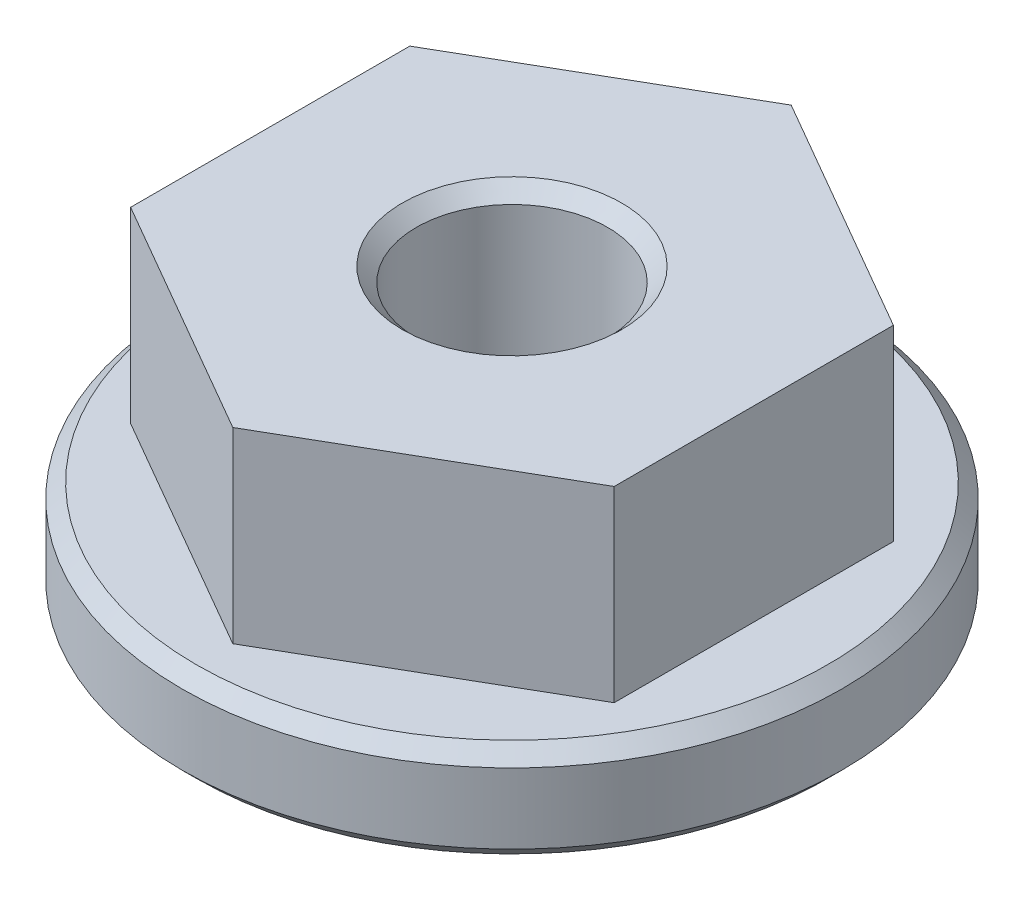
from build123d import *

# Parameters (mm, degrees)
SKETCH1_R             = 5.953125
BOSS_EXTRUDE1_DEPTH   = 1.778
BOSS_EXTRUDE2_DEPTH   = 3.381375
F_8_32_TAPPED_HOLE1_D = 3.4544
CHAMFER1_SIZE         = 0.254


with BuildPart() as part:
    # Sketch1 → Boss-Extrude1 (new body)
    with BuildSketch(Plane(origin=(0, 0, 0), x_dir=(1, 0, 0), z_dir=(0, 1, 0))):
        Circle(SKETCH1_R)
    extrude(amount=BOSS_EXTRUDE1_DEPTH)

    # Sketch2 → Boss-Extrude2 (add)
    with BuildSketch(Plane(origin=(0, 1.778, 0), x_dir=(1, 0, 0), z_dir=(0, 1, 0))):
        Polygon((4.365625, -2.520494769), (4.365625, 2.520494769), (0, 5.040989538), (-4.365625, 2.520494769), (-4.365625, -2.520494769), (0, -5.040989538), align=None)
    extrude(amount=BOSS_EXTRUDE2_DEPTH)

    # #8-32 Tapped Hole1 (through all)
    with Locations(Plane(origin=(0, 5.159375, 0), x_dir=(1, 0, 0), z_dir=(0, 1, 0))):
        with Locations((0, 0)):
            Hole(F_8_32_TAPPED_HOLE1_D / 2)

    # Chamfer1
    chamfer1_edges = [part.edges().sort_by_distance(p)[0] for p in [
        (-5.953125, 0, 0),
        (1.7272, 5.159375, 0),
        (1.7272, 0, 0),
        (-5.953125, 1.778, 0),
    ]]
    chamfer(chamfer1_edges, length=CHAMFER1_SIZE)


solid = part.part
